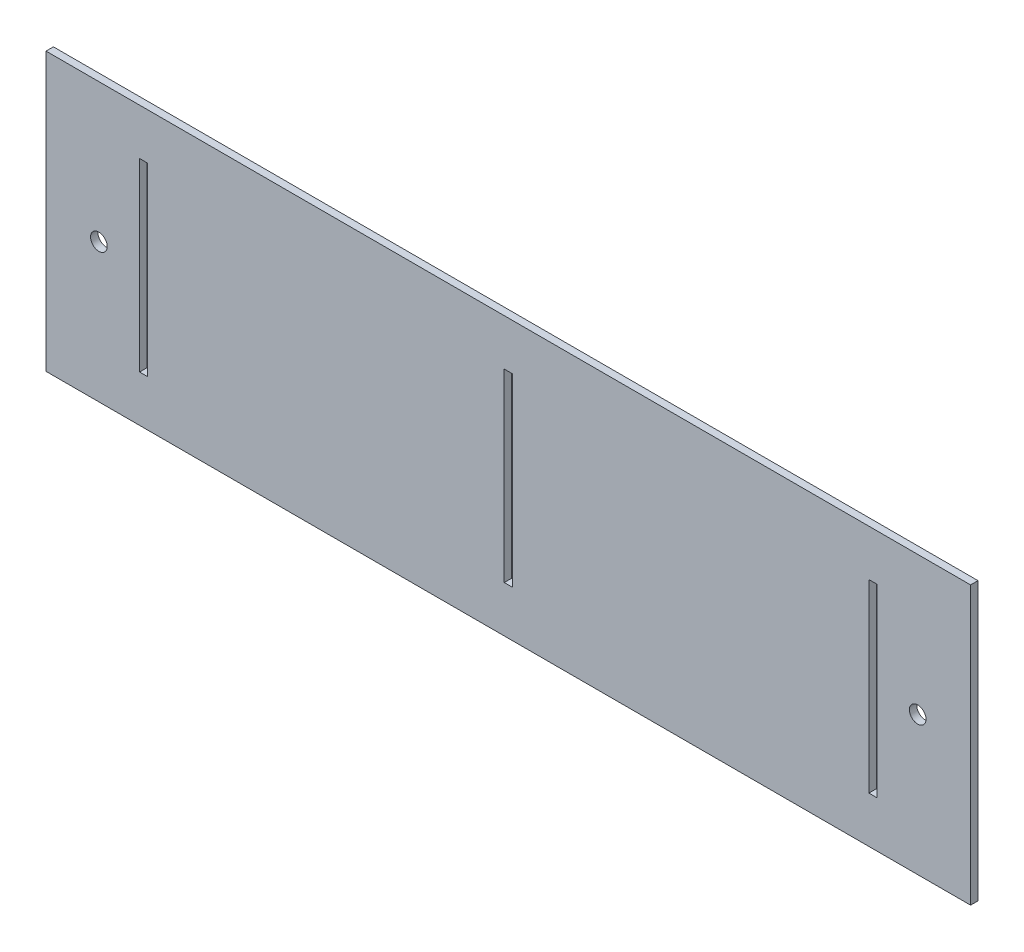
from build123d import *

# Parameters (mm, degrees)
SKETCH_2_W               = 250
SKETCH_2_H               = 75
EXTRUDE_3_DEPTH          = 2
CUT_EXTRUDE_1_DEPTH      = 2
CUT_EXTRUDE_1_DEPTH_BACK = 2
SKETCH_4_W               = 2.2
SKETCH_4_H               = 50
CUT_EXTRUDE_2_DEPTH      = 2
CUT_EXTRUDE_2_DEPTH_BACK = 10
SKETCH_5_R               = 2.25


with BuildPart() as part:
    # 草图2 → 凸台-拉伸3 (new body)
    with BuildSketch(Plane.XY):
        with Locations((51.318241286, 40.884671024)):
            Rectangle(SKETCH_2_W, SKETCH_2_H)
    extrude(amount=EXTRUDE_3_DEPTH)

    # 草图4 → 切除-拉伸1 (cut, two sides: drawn at the far end of the back side and taken through both)
    with BuildSketch(Plane.XY.offset(-CUT_EXTRUDE_1_DEPTH_BACK)):
        with Locations((149.918241286, 40.884671024)):
            Rectangle(SKETCH_4_W, SKETCH_4_H)
        with Locations((-47.281758714, 40.884671024)):
            Rectangle(SKETCH_4_W, SKETCH_4_H)
        with Locations((51.318241286, 40.884671024)):
            Rectangle(SKETCH_4_W, SKETCH_4_H)
    extrude(amount=CUT_EXTRUDE_1_DEPTH + CUT_EXTRUDE_1_DEPTH_BACK, mode=Mode.SUBTRACT)

    # 草图5 → 切除-拉伸2 (cut, two sides: drawn at the far end of the back side and taken through both)
    with BuildSketch(Plane.XY.offset(-CUT_EXTRUDE_2_DEPTH_BACK)):
        with Locations((-59.381758714, 40.884671024)):
            Circle(SKETCH_5_R)
        with Locations((162.018241286, 40.884671024)):
            Circle(SKETCH_5_R)
    extrude(amount=CUT_EXTRUDE_2_DEPTH + CUT_EXTRUDE_2_DEPTH_BACK, mode=Mode.SUBTRACT)


solid = part.part
